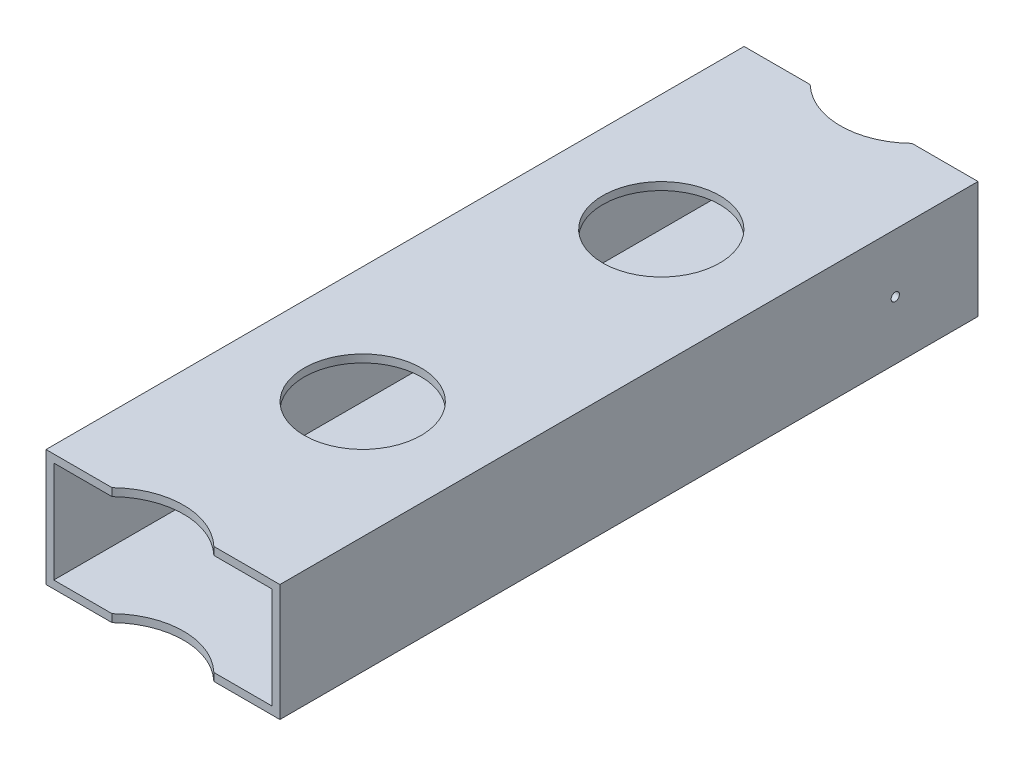
from build123d import *

# Parameters (mm, degrees)
SKETCH1_W           = 76.2
SKETCH1_H           = 38.1
SKETCH1_W_2         = 71.12
SKETCH1_H_2         = 33.02
EXTRUDE_THIN1_DEPTH = 261.62
CUT_EXTRUDE2_DEPTH  = 39.1
SKETCH4_R           = 19.05
CUT_EXTRUDE3_DEPTH  = 39.1
SKETCH5_R           = 1.3462
CUT_EXTRUDE6_DEPTH  = 77.2


with BuildPart() as part:
    # Sketch1 → Extrude-Thin1 (new body)
    with BuildSketch(Plane.XY):
        Rectangle(SKETCH1_W, SKETCH1_H)
        Rectangle(SKETCH1_W_2, SKETCH1_H_2, mode=Mode.SUBTRACT)
    extrude(amount=EXTRUDE_THIN1_DEPTH)

    # Sketch3 → Cut-Extrude2 (cut, through all)
    with BuildSketch(Plane(origin=(0, 19.05, 0), x_dir=(1, 0, 0), z_dir=(0, 1, 0))):
        with BuildLine():
            ThreePointArc((23.8125, -261.62), (21.931629786, -252.344291339), (16.586146516, -244.53389746))
            ThreePointArc((16.586146516, -244.53389746), (0, -237.8075), (-16.586146516, -244.53389746))
            ThreePointArc((-16.586146516, -244.53389746), (-21.931629786, -252.344291339), (-23.8125, -261.62))
            Line((-23.8125, -261.62), (23.8125, -261.62))
        make_face()
        with BuildLine():
            ThreePointArc((-23.8125, -261.62), (0, -285.4325), (23.8125, -261.62))
            Line((23.8125, -261.62), (-23.8125, -261.62))
        make_face()
        with BuildLine():
            Line((38.1, -261.62), (38.1, -244.53389746))
            Line((38.1, -244.53389746), (16.586146516, -244.53389746))
            ThreePointArc((16.586146516, -244.53389746), (21.931629786, -252.344291339), (23.8125, -261.62))
            Line((23.8125, -261.62), (38.1, -261.62))
        make_face()
        with BuildLine():
            ThreePointArc((-23.8125, -261.62), (-21.931629786, -252.344291339), (-16.586146516, -244.53389746))
            Line((-16.586146516, -244.53389746), (-38.1, -244.53389746))
            Line((-38.1, -244.53389746), (-38.1, -261.62))
            Line((-38.1, -261.62), (-23.8125, -261.62))
        make_face()
        with BuildLine():
            ThreePointArc((-16.586146516, -17.08610254), (0, -23.8125), (16.586146516, -17.08610254))
            ThreePointArc((16.586146516, -17.08610254), (21.931629786, -9.275708661), (23.8125, 0))
            Line((23.8125, 0), (-23.8125, 0))
            ThreePointArc((-23.8125, 0), (-21.931629786, -9.275708661), (-16.586146516, -17.08610254))
        make_face()
        with BuildLine():
            Line((-23.8125, 0), (23.8125, 0))
            ThreePointArc((23.8125, 0), (0, 23.8125), (-23.8125, 0))
        make_face()
        with BuildLine():
            Line((-38.1, -17.08610254), (-16.586146516, -17.08610254))
            ThreePointArc((-16.586146516, -17.08610254), (-21.931629786, -9.275708661), (-23.8125, 0))
            Line((-23.8125, 0), (-38.1, 0))
            Line((-38.1, 0), (-38.1, -17.08610254))
        make_face()
        with BuildLine():
            Line((16.586146516, -17.08610254), (38.1, -17.08610254))
            Line((38.1, -17.08610254), (38.1, 0))
            Line((38.1, 0), (23.8125, 0))
            ThreePointArc((23.8125, 0), (21.931629786, -9.275708661), (16.586146516, -17.08610254))
        make_face()
    extrude(amount=-CUT_EXTRUDE2_DEPTH, mode=Mode.SUBTRACT)

    # Sketch4 → Cut-Extrude3 (cut, through all)
    with BuildSketch(Plane(origin=(0, 19.05, 0), x_dir=(1, 0, 0), z_dir=(0, 1, 0))):
        with Locations((0, -179.44639746)):
            Circle(SKETCH4_R)
        with Locations((0, -82.17360254)):
            Circle(SKETCH4_R)
    extrude(amount=-CUT_EXTRUDE3_DEPTH, mode=Mode.SUBTRACT)

    # Sketch5 → Cut-Extrude6 (cut, through all)
    with BuildSketch(Plane(origin=(38.1, 0, 0), x_dir=(0, 0, -1), z_dir=(1, 0, 0))):
        with Locations((-44.044847153, 0)):
            Circle(SKETCH5_R)
    extrude(amount=-CUT_EXTRUDE6_DEPTH, mode=Mode.SUBTRACT)


solid = part.part
